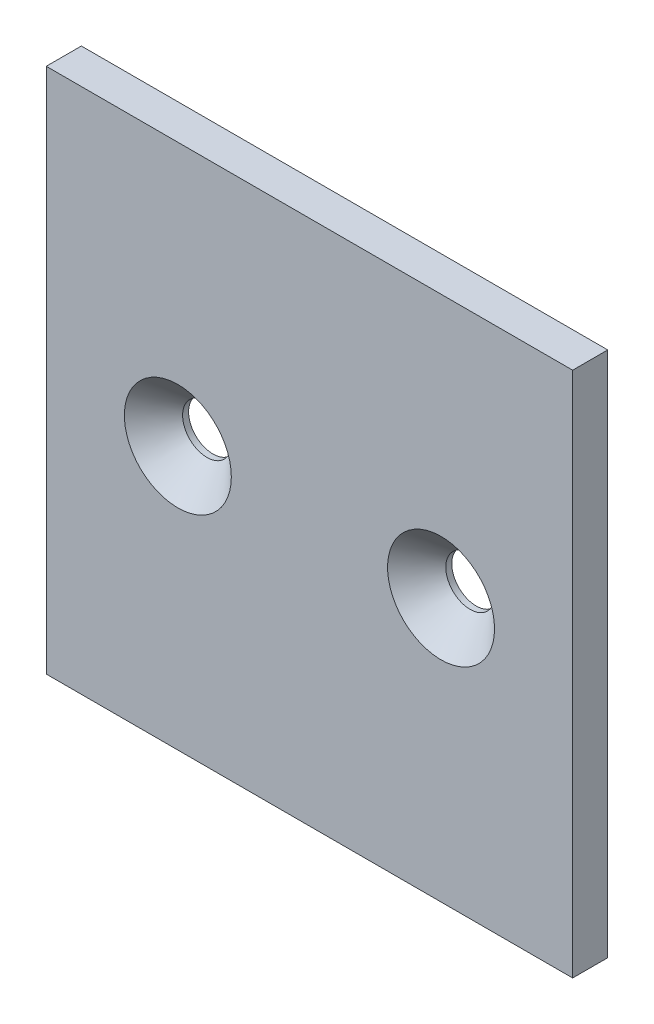
from build123d import *

# Parameters (mm, degrees)
SKETCH1_W           = 90
SKETCH1_H           = 90
SKETCH1_R           = 4.1656
BOSS_EXTRUDE1_DEPTH = 3
SKETCH2_R           = 9.144
CUT_EXTRUDE1_DEPTH  = 7
CUT_EXTRUDE1_TAPER  = 45


with BuildPart() as part:
    # Sketch1 → Boss-Extrude1 (new body, symmetric)
    with BuildSketch(Plane.XY):
        with Locations((45, 45)):
            Rectangle(SKETCH1_W, SKETCH1_H)
        with Locations((22.5, 45)):
            Circle(SKETCH1_R, mode=Mode.SUBTRACT)
        with Locations((67.5, 45)):
            Circle(SKETCH1_R, mode=Mode.SUBTRACT)
    extrude(amount=BOSS_EXTRUDE1_DEPTH, both=True)

    # Sketch2 → Cut-Extrude1 (cut, through all)
    with BuildSketch(Plane.XY.offset(3)):
        with Locations((22.5, 45)):
            Circle(SKETCH2_R)
        with Locations((67.5, 45)):
            Circle(SKETCH2_R)
    extrude(amount=-CUT_EXTRUDE1_DEPTH, taper=CUT_EXTRUDE1_TAPER, mode=Mode.SUBTRACT)


solid = part.part
